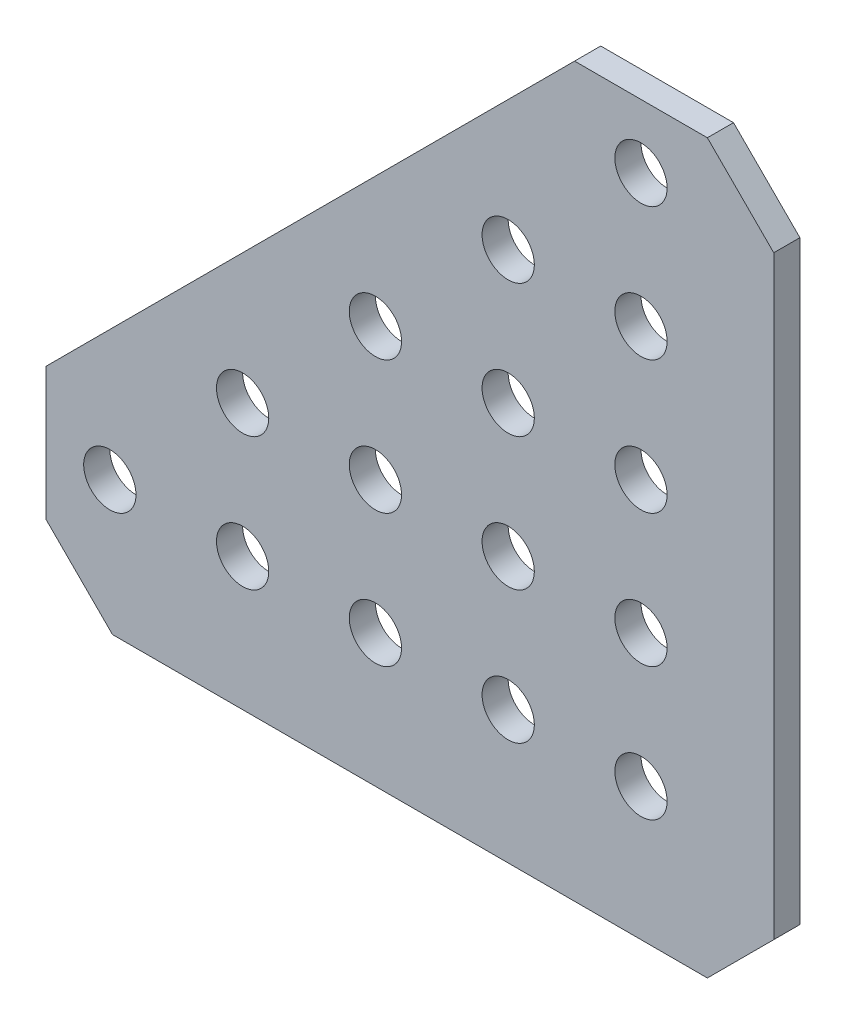
from build123d import *

# Parameters (mm, degrees)
SKETCH1_R           = 2.5
BOSS_EXTRUDE1_DEPTH = 2.5


with BuildPart() as part:
    # Sketch1 → Boss-Extrude1 (new body)
    with BuildSketch(Plane(origin=(0, 0, -1.25), x_dir=(-1, 0, 0), z_dir=(0, 0, -1))):
        Polygon((-6.35, -12.7), (50.546, -12.7), (56.896, -6.35), (56.896, 6.35), (6.35, 56.896), (-6.35, 56.896), (-12.7, 50.546), (-12.7, -6.35), align=None)
        with Locations((0, 12.7)):
            Circle(SKETCH1_R, mode=Mode.SUBTRACT)
        with Locations((0, 25.4)):
            Circle(SKETCH1_R, mode=Mode.SUBTRACT)
        with Locations((12.7, 0)):
            Circle(SKETCH1_R, mode=Mode.SUBTRACT)
        with Locations((25.4, 0)):
            Circle(SKETCH1_R, mode=Mode.SUBTRACT)
        Circle(SKETCH1_R, mode=Mode.SUBTRACT)
        with Locations((50.8, 0)):
            Circle(SKETCH1_R, mode=Mode.SUBTRACT)
        with Locations((38.1, 0)):
            Circle(SKETCH1_R, mode=Mode.SUBTRACT)
        with Locations((0, 50.8)):
            Circle(SKETCH1_R, mode=Mode.SUBTRACT)
        with Locations((0, 38.1)):
            Circle(SKETCH1_R, mode=Mode.SUBTRACT)
        with Locations((12.7, 12.7)):
            Circle(SKETCH1_R, mode=Mode.SUBTRACT)
        with Locations((12.7, 25.4)):
            Circle(SKETCH1_R, mode=Mode.SUBTRACT)
        with Locations((12.7, 38.1)):
            Circle(SKETCH1_R, mode=Mode.SUBTRACT)
        with Locations((25.4, 12.7)):
            Circle(SKETCH1_R, mode=Mode.SUBTRACT)
        with Locations((25.4, 25.4)):
            Circle(SKETCH1_R, mode=Mode.SUBTRACT)
        with Locations((38.1, 12.7)):
            Circle(SKETCH1_R, mode=Mode.SUBTRACT)
    extrude(amount=-BOSS_EXTRUDE1_DEPTH)


solid = part.part
